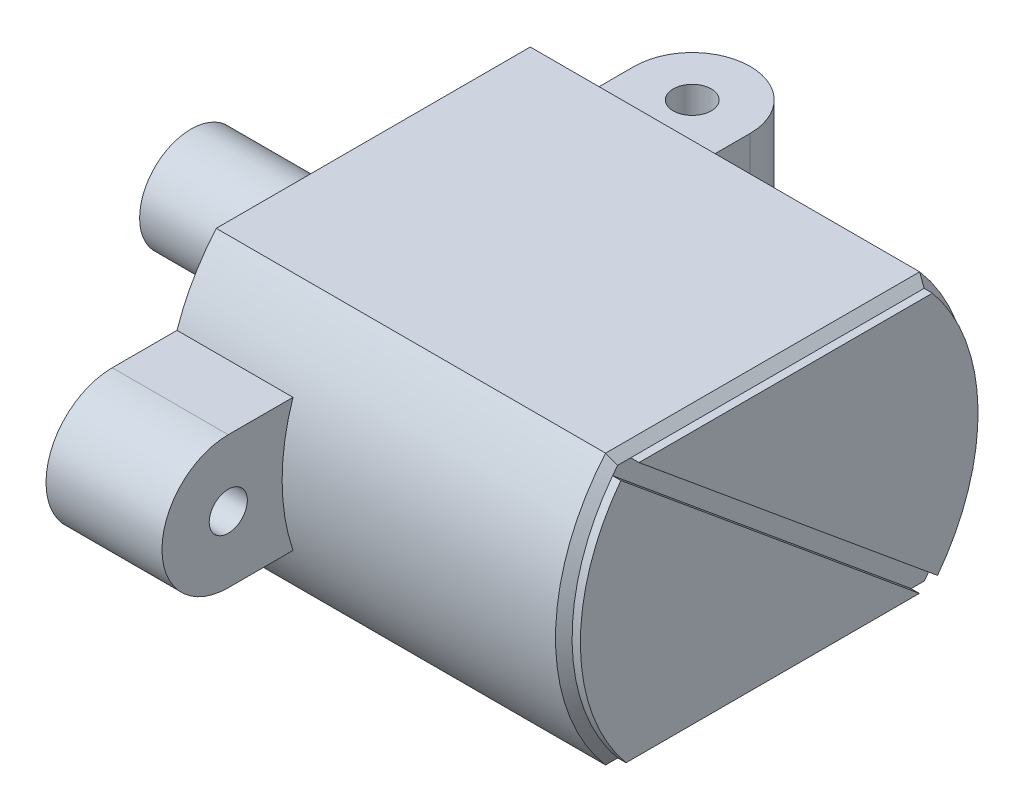
from build123d import *

# Parameters (mm, degrees)
EXTRUDE_1_DEPTH = 24
SKETCH_2_R      = 1.15
EXTRUDE_2_DEPTH = 7
SKETCH_3_R      = 1.15
EXTRUDE_3_DEPTH = 4
SKETCH_4_R      = 3.1
EXTRUDE_4_DEPTH = 11
CHAMFER_4_SIZE  = 0.5
EXTRUDE_5_DEPTH = 0.5


with BuildPart() as part:
    # 草图1 → 凸台-拉伸1 (new body)
    with BuildSketch(Plane(origin=(0, 0, 0), x_dir=(0, 0, -1), z_dir=(1, 0, 0))):
        with BuildLine():
            Line((9.477737072, -8.15), (-9.477737072, -8.15))
            ThreePointArc((-9.477737072, -8.15), (-12.5, 0), (-9.477737072, 8.15))
            Line((-9.477737072, 8.15), (9.477737072, 8.15))
            ThreePointArc((9.477737072, 8.15), (12.5, 0), (9.477737072, -8.15))
        make_face()
    extrude(amount=EXTRUDE_1_DEPTH)

    # 草图2 → 凸台-拉伸2 (add)
    with BuildSketch(Plane.ZY):
        with BuildLine():
            Line((0, 4), (15.75, 4))
            ThreePointArc((15.75, 4), (19.75, 0), (15.75, -4))
            Line((15.75, -4), (0, -4))
            ThreePointArc((0, -4), (-4, 0), (0, 4))
        make_face()
        with Locations((15.75, 0)):
            Circle(SKETCH_2_R, mode=Mode.SUBTRACT)
    extrude(amount=-EXTRUDE_2_DEPTH)

    # 草图3 → 凸台-拉伸3 (add, symmetric)
    with BuildSketch(Plane(origin=(0, 0, 0), x_dir=(1, 0, 0), z_dir=(0, 1, 0))):
        with BuildLine():
            Line((0, 0), (0, 15.75))
            ThreePointArc((0, 15.75), (3.5, 19.25), (7, 15.75))
            Line((7, 15.75), (7, 0))
            ThreePointArc((7, 0), (3.5, -3.5), (0, 0))
        make_face()
        with Locations((3.5, 15.75)):
            Circle(SKETCH_3_R, mode=Mode.SUBTRACT)
    extrude(amount=EXTRUDE_3_DEPTH, both=True)

    # 草图4 → 凸台-拉伸4 (add)
    with BuildSketch(Plane.ZY):
        Circle(SKETCH_4_R)
    extrude(amount=EXTRUDE_4_DEPTH)

    # 倒角4
    chamfer_4_edges = [part.edges().sort_by_distance(p)[0] for p in [
        (24, 0, -12.5),
        (24, 8.15, 0),
        (24, 0, 12.5),
        (24, -8.15, 0),
    ]]
    chamfer(chamfer_4_edges, length=CHAMFER_4_SIZE)

    # 草图5 → 凸台-拉伸5 (add)
    with BuildSketch(Plane(origin=(24, 0, 0), x_dir=(0, 0, -1), z_dir=(1, 0, 0))):
        with BuildLine():
            Line((-9.556125253, 7.258131313), (8.461090538, -7.65))
            Line((8.461090538, -7.65), (-9.245404264, -7.65))
            ThreePointArc((-9.245404264, -7.65), (-11.997394419, -0.250054295), (-9.556125253, 7.258131313))
        make_face()
        with BuildLine():
            Line((9.245404264, 7.65), (-8.461090538, 7.65))
            Line((-8.461090538, 7.65), (9.556125253, -7.258131313))
            ThreePointArc((9.556125253, -7.258131313), (11.997394419, 0.250054295), (9.245404264, 7.65))
        make_face()
    extrude(amount=EXTRUDE_5_DEPTH)


solid = part.part
